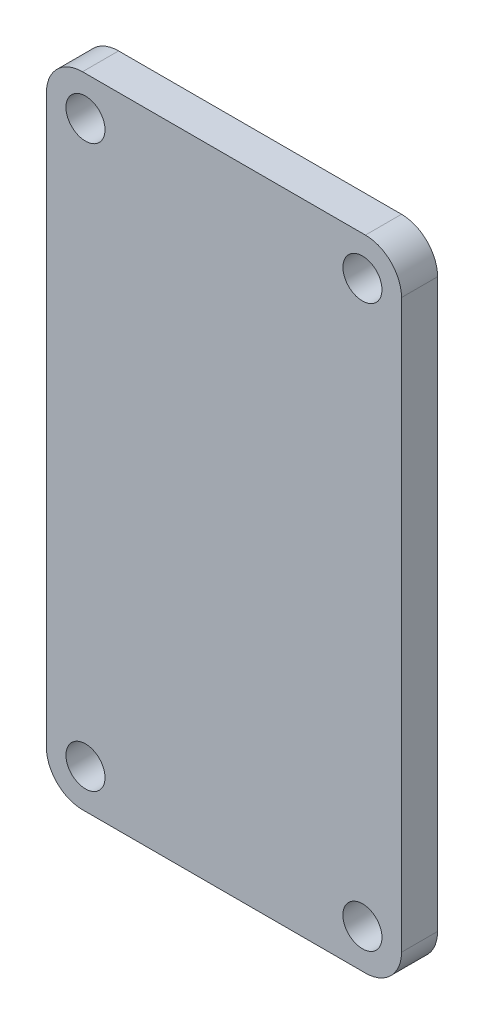
from build123d import *

# Parameters (mm, degrees)
SKETCH1_W           = 25
SKETCH1_H           = 45
SKETCH1_R           = 1.375
BOSS_EXTRUDE1_DEPTH = 2.54
FILLET1_R           = 2.54


with BuildPart() as part:
    # Sketch1 → Boss-Extrude1 (new body)
    with BuildSketch(Plane.XY):
        with Locations((12.5, -22.5)):
            Rectangle(SKETCH1_W, SKETCH1_H)
        with Locations((2.75, -2.75)):
            Circle(SKETCH1_R, mode=Mode.SUBTRACT)
        with Locations((2.75, -42.25)):
            Circle(SKETCH1_R, mode=Mode.SUBTRACT)
        with Locations((22.25, -42.25)):
            Circle(SKETCH1_R, mode=Mode.SUBTRACT)
        with Locations((22.25, -2.75)):
            Circle(SKETCH1_R, mode=Mode.SUBTRACT)
    extrude(amount=BOSS_EXTRUDE1_DEPTH)

    # Fillet1
    fillet1_edges = [part.edges().sort_by_distance(p)[0] for p in [
        (0, 0, 1.27),
        (25, 0, 1.27),
        (25, -45, 1.27),
        (0, -45, 1.27),
    ]]
    fillet(fillet1_edges, radius=FILLET1_R)


solid = part.part
